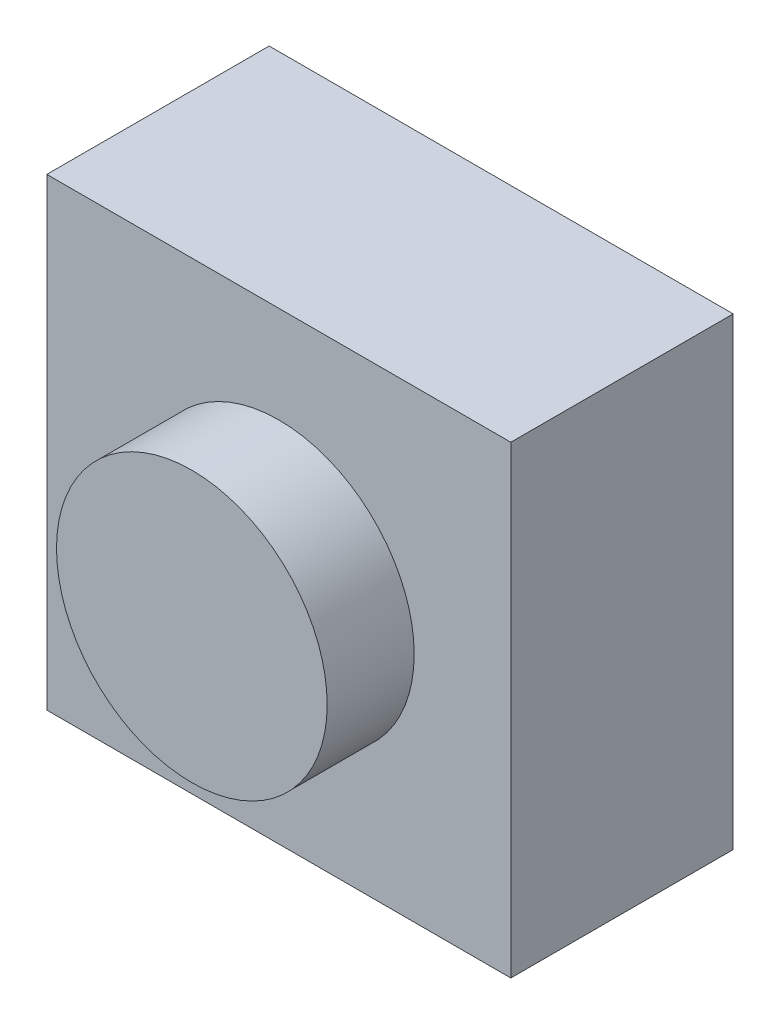
from build123d import *

# Parameters (mm, degrees)
SKETCH1_W           = 6.096
SKETCH1_H           = 6.096
BOSS_EXTRUDE1_DEPTH = 2.921
SKETCH2_R           = 1.778
BOSS_EXTRUDE2_DEPTH = 1.143


with BuildPart() as part:
    # Sketch1 → Boss-Extrude1 (new body)
    with BuildSketch(Plane.XY):
        with Locations((-146.95080282, 79.929090846)):
            Rectangle(SKETCH1_W, SKETCH1_H)
    extrude(amount=BOSS_EXTRUDE1_DEPTH)

    # Sketch2 → Boss-Extrude2 (add)
    with BuildSketch(Plane.XY.offset(2.921)):
        with Locations((-146.95080282, 79.929090846)):
            Circle(SKETCH2_R)
    extrude(amount=BOSS_EXTRUDE2_DEPTH)


solid = part.part
